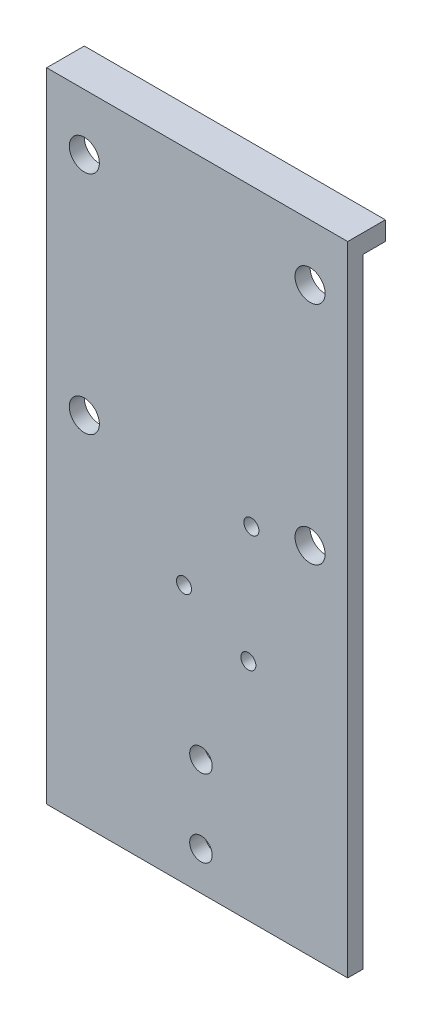
from build123d import *

# Parameters (mm, degrees)
ESQUISSE1_W             = 80
ESQUISSE1_H             = 169.5
BOSS_EXTRU_1_DEPTH      = 4
ESQUISSE2_R             = 4
ENL_V_MAT_EXTRU_1_DEPTH = 5
ESQUISSE5_R             = 3
ENL_V_MAT_EXTRU_2_DEPTH = 5
ESQUISSE6_W             = 80
ESQUISSE6_H             = 5
BOSS_EXTRU_2_DEPTH      = 6
ESQUISSE7_R             = 2
ENL_V_MAT_EXTRU_5_DEPTH = 11


with BuildPart() as part:
    # Esquisse1 → Boss.-Extru.1 (new body)
    with BuildSketch(Plane.XY):
        with Locations((10.990966959, -33.844488189)):
            Rectangle(ESQUISSE1_W, ESQUISSE1_H)
    extrude(amount=BOSS_EXTRU_1_DEPTH)

    # Esquisse2 → Enlèv. mat.-Extru.1 (cut, through all)
    with BuildSketch(Plane.XY.offset(4)):
        with Locations((-19.009033041, 35.905511811)):
            Circle(ESQUISSE2_R)
        with Locations((40.990966959, 35.905511811)):
            Circle(ESQUISSE2_R)
        with Locations((-19.009033041, -24.094488189)):
            Circle(ESQUISSE2_R)
        with Locations((40.990966959, -24.094488189)):
            Circle(ESQUISSE2_R)
    extrude(amount=-ENL_V_MAT_EXTRU_1_DEPTH, mode=Mode.SUBTRACT)

    # Esquisse5 → Enlèv. mat.-Extru.2 (cut, through all)
    with BuildSketch(Plane.XY.offset(4)):
        with Locations((11.990966959, -108.344488189)):
            Circle(ESQUISSE5_R)
        with Locations((11.990966959, -87.844488189)):
            Circle(ESQUISSE5_R)
    extrude(amount=-ENL_V_MAT_EXTRU_2_DEPTH, mode=Mode.SUBTRACT)

    # Esquisse6 → Boss.-Extru.2 (add)
    with BuildSketch(Plane(origin=(0, 0, 0), x_dir=(-1, 0, 0), z_dir=(0, 0, -1))):
        with Locations((-10.990966959, 48.405511811)):
            Rectangle(ESQUISSE6_W, ESQUISSE6_H)
    extrude(amount=BOSS_EXTRU_2_DEPTH)

    # Esquisse7 → Enlèv. mat.-Extru.5 (cut, through all)
    with BuildSketch(Plane.XY.offset(4)):
        with Locations((7.490966959, -49.894488189)):
            Circle(ESQUISSE7_R)
        with Locations((25.390966959, -27.494488189)):
            Circle(ESQUISSE7_R)
        with Locations((24.590966959, -58.894488189)):
            Circle(ESQUISSE7_R)
    extrude(amount=-ENL_V_MAT_EXTRU_5_DEPTH, mode=Mode.SUBTRACT)


solid = part.part
